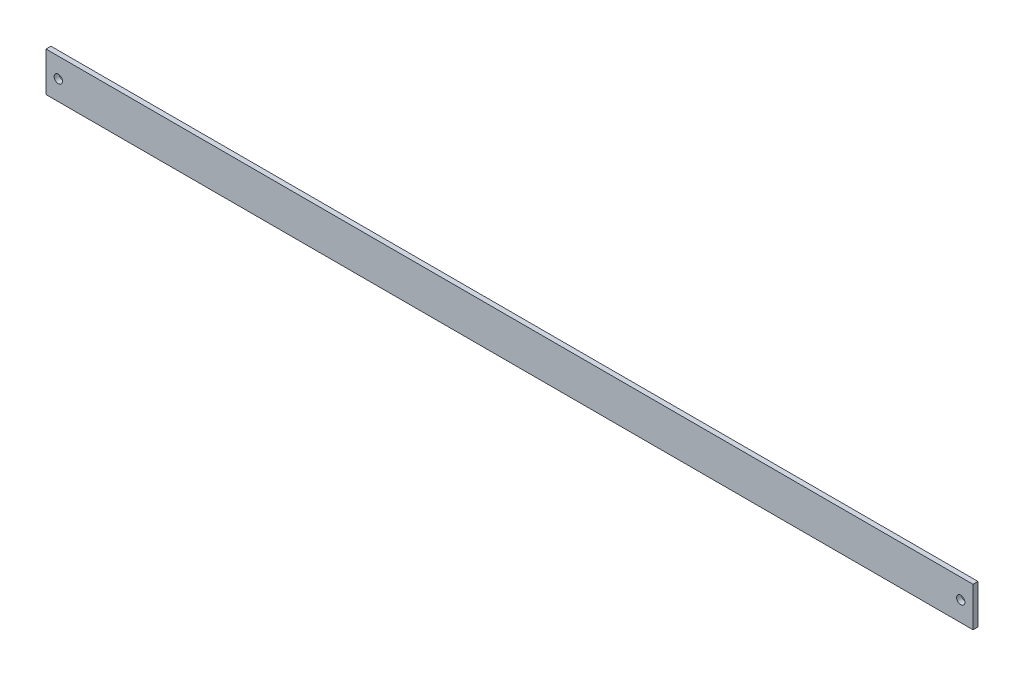
from build123d import *

# Parameters (mm, degrees)
SKETCH1_W           = 3.175
SKETCH1_H           = 25.4
BOSS_EXTRUDE1_DEPTH = 596.9
CUT_EXTRUDE1_REACH  = 5.175
SKETCH2_R           = 2.667


with BuildPart() as part:
    # Sketch1 → Boss-Extrude1 (new body)
    with BuildSketch(Plane(origin=(0, 0, 0), x_dir=(0, 0, -1), z_dir=(1, 0, 0))):
        with Locations((1.5875, 12.7)):
            Rectangle(SKETCH1_W, SKETCH1_H)
    extrude(amount=BOSS_EXTRUDE1_DEPTH)

    # Sketch2 → Cut-Extrude1 (cut, up to next)
    with BuildSketch(Plane.XY, mode=Mode.PRIVATE) as cut_extrude1_sk1:
        with Locations((7.9375, 12.7)):
            Circle(SKETCH2_R)
    cut_extrude1_tool1 = extrude(cut_extrude1_sk1.sketch, amount=-CUT_EXTRUDE1_REACH, mode=Mode.PRIVATE) & part.part
    add(cut_extrude1_tool1.solids().sort_by_distance((7.9375, 12.7, 0))[0], mode=Mode.SUBTRACT)
    # Sketch2 → Cut-Extrude1 (cut, up to next)
    with BuildSketch(Plane.XY, mode=Mode.PRIVATE) as cut_extrude1_sk2:
        with Locations((588.9625, 12.7)):
            Circle(SKETCH2_R)
    cut_extrude1_tool2 = extrude(cut_extrude1_sk2.sketch, amount=-CUT_EXTRUDE1_REACH, mode=Mode.PRIVATE) & part.part
    add(cut_extrude1_tool2.solids().sort_by_distance((588.9625, 12.7, 0))[0], mode=Mode.SUBTRACT)


solid = part.part
